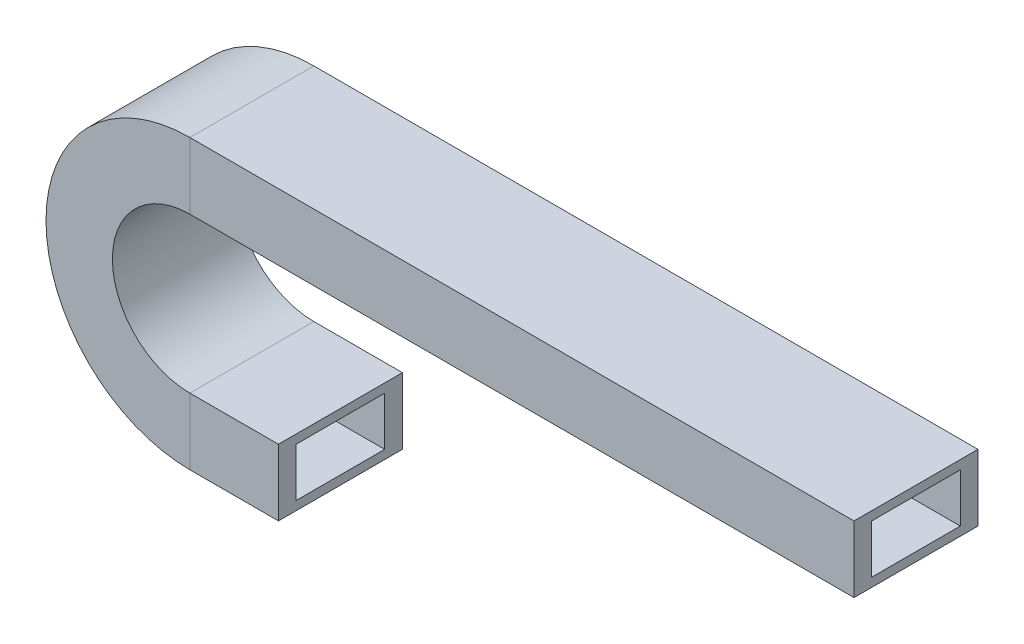
from build123d import *

# Parameters (mm, degrees)
SKETCH2_W   = 28
SKETCH2_H   = 15
SKETCH2_W_2 = 20
SKETCH2_H_2 = 11


with BuildPart() as part:
    # Sweep1: sweep along a path in Sketch1
    with BuildLine(Plane.XY) as sweep1_path:
        Line((0, 0), (-20, 0))
        ThreePointArc((-20, 0), (-45, 25), (-20, 50))
        Line((-20, 50), (130, 50))
    # Sketch2 → Sweep1 (sweep)
    with BuildSketch(Plane(origin=(0, 0, 0), x_dir=(0, 0, -1), z_dir=(1, 0, 0))):
        Rectangle(SKETCH2_W, SKETCH2_H)
        Rectangle(SKETCH2_W_2, SKETCH2_H_2, mode=Mode.SUBTRACT)
    sweep(path=sweep1_path.line)


solid = part.part
